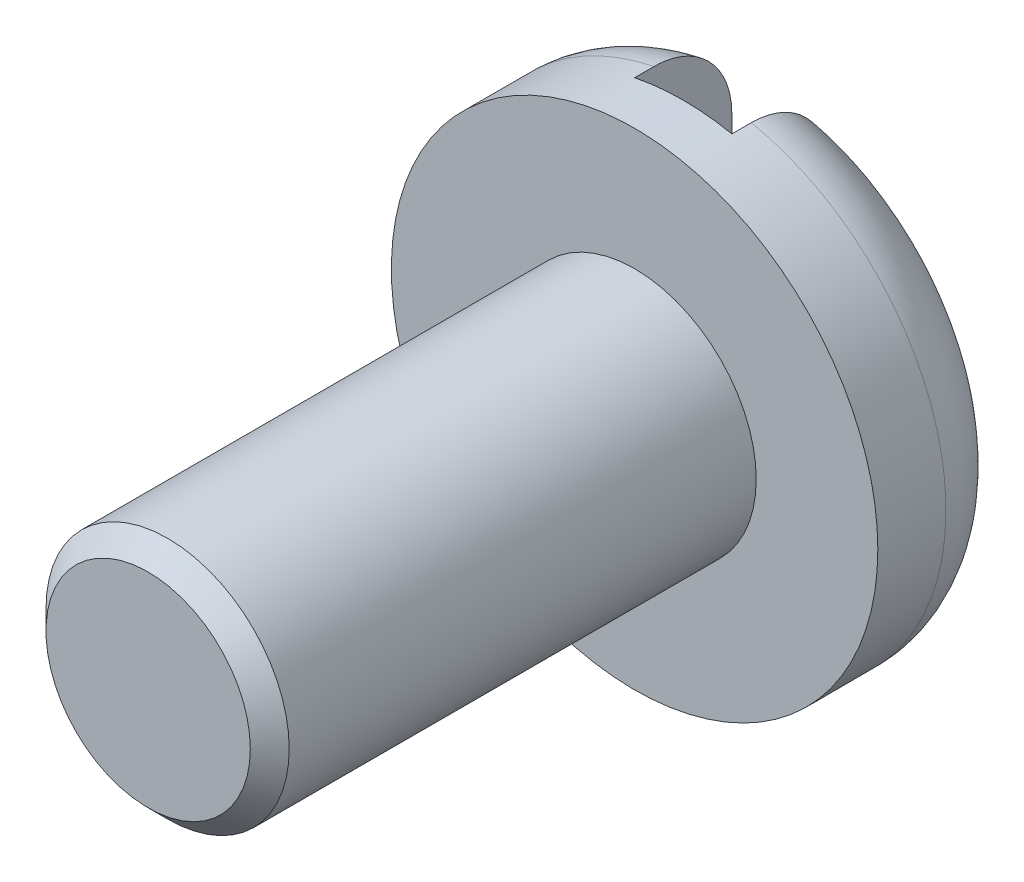
from build123d import *

# Parameters (mm, degrees)
ESQUISSE1_R                  = 2.5
BASE_EXTRUSION_DEPTH         = 1.5
CONG_1_R                     = 0.8
ESQUISSE2_R                  = 1.25
BOSS_EXTRU_1_DEPTH           = 5
CHANFREIN1_SIZE              = 0.2
ESQUISSE3_W                  = 1
ESQUISSE3_H                  = 1
ENL_V_MAT_EXTRU_1_DEPTH      = 3.5
ENL_V_MAT_EXTRU_1_DEPTH_BACK = 3.5


with BuildPart() as part:
    # Esquisse1 → Base-Extrusion (new body)
    with BuildSketch(Plane.XY):
        Circle(ESQUISSE1_R)
    extrude(amount=BASE_EXTRUSION_DEPTH)

    # Cong_1
    cong_1_edges = [part.edges().sort_by_distance(p)[0] for p in [
        (-2.5, 0, 0),
    ]]
    fillet(cong_1_edges, radius=CONG_1_R)

    # Esquisse2 → Boss.-Extru.1 (add)
    with BuildSketch(Plane.XY.offset(1.5)):
        Circle(ESQUISSE2_R)
    extrude(amount=BOSS_EXTRU_1_DEPTH)

    # Chanfrein1
    chanfrein1_edges = [part.edges().sort_by_distance(p)[0] for p in [
        (-1.25, 0, 6.5),
    ]]
    chamfer(chanfrein1_edges, length=CHANFREIN1_SIZE)

    # Esquisse3 → Enl_v. mat.-Extru.1 (cut, two sides)
    with BuildSketch(Plane(origin=(0, 0, 0), x_dir=(1, 0, 0), z_dir=(0, 1, 0))) as enl_v_mat_extru_1_sk:
        with Locations((0, -0.5)):
            Rectangle(ESQUISSE3_W, ESQUISSE3_H)
    extrude(amount=ENL_V_MAT_EXTRU_1_DEPTH, mode=Mode.SUBTRACT)
    extrude(enl_v_mat_extru_1_sk.sketch, amount=-ENL_V_MAT_EXTRU_1_DEPTH_BACK, mode=Mode.SUBTRACT)


solid = part.part
